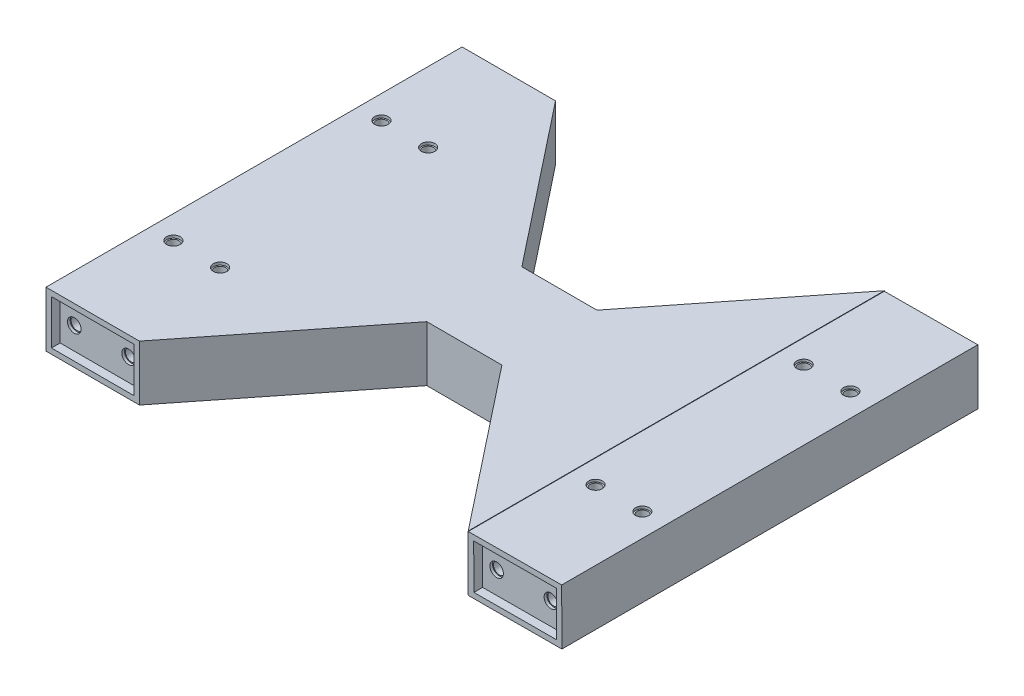
from build123d import *

# Parameters (mm, degrees)
SKETCH1_W                          = 34.4
SKETCH1_H                          = 20.4
SKETCH1_W_2                        = 30.4
SKETCH1_H_2                        = 16.4
BOSS_EXTRUDE1_DEPTH                = 3.2
BOSS_EXTRUDE1_2_DEPTH              = 3.2
SKETCH4_W                          = 34.4
SKETCH4_H                          = 20.4
BOSS_EXTRUDE2_DEPTH                = 150
SKETCH5_W                          = 30.4
SKETCH5_H                          = 16.4
CUT_EXTRUDE2_DEPTH                 = 3.2
BOSS_EXTRUDE4_REACH                = 157.551
SKETCH13_W                         = 153.2
SKETCH13_H                         = 20.4
SKETCH2_R                          = 2.15
CUT_EXTRUDE5_DEPTH                 = 147
SKETCH18_R                         = 2.5
CUT_EXTRUDE6_DEPTH                 = 1
SKETCH19_R                         = 2.5
CUT_EXTRUDE7_DEPTH                 = 1
F_4_0_4_DIAMETER_HOLE1_D           = 4
F_4_0_4_DIAMETER_HOLE1_ON_FACE_2_D = 4
F_4_0_4_DIAMETER_HOLE1_ON_FACE_3_D = 4
SKETCH22_R                         = 2.5
CUT_EXTRUDE10_DEPTH                = 1
F_4_0_4_DIAMETER_HOLE2_D           = 4
SKETCH28_R                         = 2.5
CUT_EXTRUDE11_DEPTH                = 1
CUT_EXTRUDE12_DEPTH                = 21.566702188


with BuildPart() as part:
    # Sketch1 → Boss-Extrude1 (new body)
    with BuildSketch(Plane.XY):
        with Locations((-13.13286664, 8.093964388)):
            Rectangle(SKETCH1_W, SKETCH1_H)
        with Locations((-13.13286664, 8.093964388)):
            Rectangle(SKETCH1_W_2, SKETCH1_H_2, mode=Mode.SUBTRACT)
    extrude(amount=BOSS_EXTRUDE1_DEPTH)



with BuildPart() as body_2:
    # Sketch1 → Boss-Extrude1 2 (new body)
    with BuildSketch(Plane.XY):
        Polygon((125.217994466, -2.2727378), (159.617685817, -2.127015635), (159.531269184, 18.272801329), (125.131577833, 18.127079165), align=None)
        Polygon((127.209504302, -0.264283525), (157.609231543, -0.135505799), (157.539759348, 16.264347055), (127.140032108, 16.135569328), align=None, mode=Mode.SUBTRACT)
    extrude(amount=BOSS_EXTRUDE1_2_DEPTH)


with BuildPart() as part_1:
    add(part.part)

    add(body_2.part)  # Boss-Extrude2 merges body 2
    # Sketch4 → Boss-Extrude2 (add)
    with BuildSketch(Plane.XY.offset(3.2)):
        with Locations((-13.13286664, 8.093964388)):
            Rectangle(SKETCH4_W, SKETCH4_H)
        Polygon((125.131577833, 18.127079165), (125.217994466, -2.2727378), (159.617685817, -2.127015635), (159.531269184, 18.272801329), align=None)
    extrude(amount=BOSS_EXTRUDE2_DEPTH)

    # Sketch5 → Cut-Extrude2 (cut)
    with BuildSketch(Plane.XY.offset(153.2)):
        with Locations((-13.13286664, 8.093964388)):
            Rectangle(SKETCH5_W, SKETCH5_H)
        Polygon((157.539759348, 16.264347055), (127.140032108, 16.135569328), (127.209504302, -0.264283525), (157.609231543, -0.135505799), align=None)
    extrude(amount=-CUT_EXTRUDE2_DEPTH, mode=Mode.SUBTRACT)

    # Boss-Extrude4: up to this face of the body (flat: up to its plane)
    boss_extrude4_end = Plane(part_1.part.faces().sort_by_distance((125.17478615, 7.927170683, 76.6))[0])
    # Sketch13 → Boss-Extrude4 (add, up to the picked face)
    with BuildSketch(Plane(origin=(4.06713336, 0, 0), x_dir=(0, 0, -1), z_dir=(1, 0, 0)), mode=Mode.PRIVATE) as boss_extrude4_sk1:
        with Locations((-76.6, 8.093964388)):
            Rectangle(SKETCH13_W, SKETCH13_H)
    boss_extrude4_tool1 = split(extrude(boss_extrude4_sk1.sketch, amount=BOSS_EXTRUDE4_REACH, mode=Mode.PRIVATE), bisect_by=boss_extrude4_end, keep=Keep.BOTH, mode=Mode.PRIVATE)
    add(boss_extrude4_tool1.solids().sort_by_distance((4.067133, 8.093964, 76.6))[0])

    # Sketch2 → Cut-Extrude5 (cut)
    with BuildSketch(Plane.XY.offset(3)):
        with Locations((-23.13286664, 8.093964388)):
            Circle(SKETCH2_R)
        with Locations((-3.13286664, 8.093964388)):
            Circle(SKETCH2_R)
        with Locations((132.374721549, 7.95767067)):
            Circle(SKETCH2_R)
        with Locations((152.374542102, 8.042392859)):
            Circle(SKETCH2_R)
    extrude(amount=CUT_EXTRUDE5_DEPTH, mode=Mode.SUBTRACT)

    # Sketch18 → Cut-Extrude6 (cut)
    with BuildSketch(Plane(origin=(0, 0, 3.2), x_dir=(-1, 0, 0), z_dir=(0, 0, -1))):
        with Locations((-132.374721549, 7.95767067)):
            Circle(SKETCH18_R)
        with Locations((-152.374542102, 8.042392859)):
            Circle(SKETCH18_R)
        with Locations((3.13286664, 8.093964388)):
            Circle(SKETCH18_R)
        with Locations((23.13286664, 8.093964388)):
            Circle(SKETCH18_R)
    extrude(amount=-CUT_EXTRUDE6_DEPTH, mode=Mode.SUBTRACT)

    # Sketch19 → Cut-Extrude7 (cut)
    with BuildSketch(Plane.XY.offset(150)):
        with Locations((-23.13286664, 8.093964388)):
            Circle(SKETCH19_R)
        with Locations((-3.13286664, 8.093964388)):
            Circle(SKETCH19_R)
        with Locations((132.374721549, 7.95767067)):
            Circle(SKETCH19_R)
        with Locations((152.374542102, 8.042392859)):
            Circle(SKETCH19_R)
    extrude(amount=-CUT_EXTRUDE7_DEPTH, mode=Mode.SUBTRACT)

    # Ø4.0 (4) Diameter Hole1 (through all)
    with Locations(Plane(origin=(133.731500671, 18.163509706, 114.9), x_dir=(0.999991028, 0.004236109, 0), z_dir=(-0.004236109, 0.999991028, 0))):
        with Locations((0, 0)):
            Hole(F_4_0_4_DIAMETER_HOLE1_D / 2)

    # Ø4.0 (4) Diameter Hole1 on face 2 (through all)
    with Locations(Plane(origin=(150.931346347, 18.236370788, 114.9), x_dir=(0.999991028, 0.004236, 0), z_dir=(-0.004236, 0.999991028, 0))):
        with Locations((0, 0), (0, 76.6)):
            Hole(F_4_0_4_DIAMETER_HOLE1_ON_FACE_2_D / 2)

    # Ø4.0 (4) Diameter Hole1 on face 3 (through all)
    with Locations(Plane(origin=(133.731500671, 18.163509706, 38.3), x_dir=(0.999991028, 0.004236, 0), z_dir=(-0.004236, 0.999991028, 0))):
        with Locations((0, 0)):
            Hole(F_4_0_4_DIAMETER_HOLE1_ON_FACE_3_D / 2)

    # Sketch22 → Cut-Extrude10 (cut)
    with BuildSketch(Plane(origin=(329.130211322, 18.293964388, 0), x_dir=(-1, 0, 0), z_dir=(0, -1, 0))):
        with Locations((195.398710651, -114.9)):
            Circle(SKETCH22_R)
        with Locations((178.198864975, -114.9)):
            Circle(SKETCH22_R)
        with Locations((178.198864975, -38.3)):
            Circle(SKETCH22_R)
        with Locations((195.398710651, -38.3)):
            Circle(SKETCH22_R)
    extrude(amount=CUT_EXTRUDE10_DEPTH, mode=Mode.SUBTRACT)

    # Ø4.0 (4) Diameter Hole2 (through all)
    with Locations(Plane(origin=(-21.73286664, 18.293964388, 114.9), x_dir=(0, 0, 1), z_dir=(0, 1, 0))):
        with Locations((0, 0), (0, 17.2), (-76.6, 17.2), (-76.6, 0)):
            Hole(F_4_0_4_DIAMETER_HOLE2_D / 2)

    # Sketch28 → Cut-Extrude11 (cut)
    with BuildSketch(Plane(origin=(0, 18.293964388, 0), x_dir=(1, 0, 0), z_dir=(0, 1, 0))):
        with Locations((-21.73286664, -38.3)):
            Circle(SKETCH28_R)
        with Locations((-4.53286664, -38.3)):
            Circle(SKETCH28_R)
        with Locations((-21.73286664, -114.9)):
            Circle(SKETCH28_R)
        with Locations((-4.53286664, -114.9)):
            Circle(SKETCH28_R)
    extrude(amount=-CUT_EXTRUDE11_DEPTH, mode=Mode.SUBTRACT)

    # Sketch29 → Cut-Extrude12 (cut, through all)
    with BuildSketch(Plane(origin=(0, 18.293964388, 0), x_dir=(1, 0, 0), z_dir=(0, 1, 0))):
        Polygon((125.130870883, -153.2), (78.42808441, -94.1), (50.769919833, -94.1), (4.06713336, -153.2), align=None)
        Polygon((125.130870883, 0), (4.06713336, 0), (50.769919833, -59.1), (78.42808441, -59.1), align=None)
    extrude(amount=-CUT_EXTRUDE12_DEPTH, mode=Mode.SUBTRACT)


solid = part_1.part
